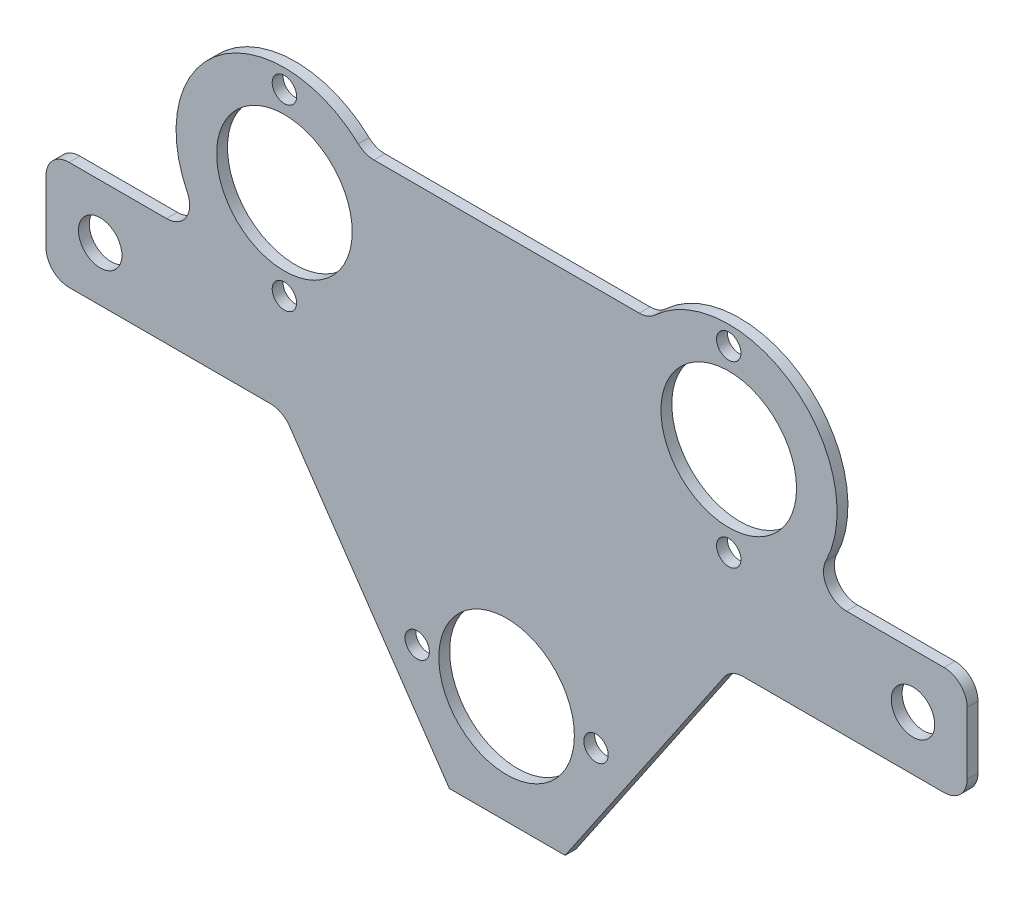
from build123d import *

# Parameters (mm, degrees)
SKETCH1_R           = 12.51
SKETCH1_R_2         = 4.01
BOSS_EXTRUDE1_DEPTH = 2
FILLET1_R           = 4.25
CUT_EXTRUDE1_REACH  = 4
SKETCH2_R           = 2.25


with BuildPart() as part:
    # Sketch1 → Boss-Extrude1 (new body)
    with BuildSketch(Plane.XY):
        with BuildLine():
            ThreePointArc((-26.243645437, 38.5), (-53.422989473, 40.673842303), (-57.51289283, 13.716189899))
            Line((-57.51289283, 13.716189899), (-54.973496399, 10))
            Line((-54.973496399, 10), (-85, 10))
            Line((-85, 10), (-85, -10))
            Line((-85, -10), (-41.306829732, -10))
            Line((-41.306829732, -10), (-10.556829732, -55))
            Line((-10.556829732, -55), (10.805406659, -55))
            Line((10.805406659, -55), (41.391170475, -10))
            Line((41.391170475, -10), (85, -10))
            Line((85, -10), (85, 10))
            Line((85, 10), (54.984843282, 10))
            Line((54.984843282, 10), (57.38463841, 13.530753113))
            ThreePointArc((57.38463841, 13.530753113), (53.511141019, 40.603568515), (26.243645437, 38.5))
            Line((26.243645437, 38.5), (-26.243645437, 38.5))
        make_face()
        with Locations((0, -35)):
            Circle(SKETCH1_R, mode=Mode.SUBTRACT)
        with Locations((-75, 0)):
            Circle(SKETCH1_R_2, mode=Mode.SUBTRACT)
        with Locations((-41, 25)):
            Circle(SKETCH1_R, mode=Mode.SUBTRACT)
        with Locations((75, 0)):
            Circle(SKETCH1_R_2, mode=Mode.SUBTRACT)
        with Locations((41, 25)):
            Circle(SKETCH1_R, mode=Mode.SUBTRACT)
    extrude(amount=BOSS_EXTRUDE1_DEPTH)

    # Fillet1
    fillet1_edges = [part.edges().sort_by_distance(p)[0] for p in [
        (-85, -10, 1),
        (-85, 10, 1),
        (85, -10, 1),
        (85, 10, 1),
        (54.984843282, 10, 1),
        (-54.973496399, 10, 1),
        (41.391170475, -10, 1),
        (-41.306829732, -10, 1),
        (26.243645437, 38.5, 1),
        (-26.243645437, 38.5, 1),
    ]]
    fillet(fillet1_edges, radius=FILLET1_R)

    # Sketch2 → Cut-Extrude1 (cut, up to next)
    with BuildSketch(Plane.XY.offset(2), mode=Mode.PRIVATE) as cut_extrude1_sk1:
        with Locations((-41, 41.5)):
            Circle(SKETCH2_R)
    cut_extrude1_tool1 = extrude(cut_extrude1_sk1.sketch, amount=-CUT_EXTRUDE1_REACH, mode=Mode.PRIVATE) & part.part
    add(cut_extrude1_tool1.solids().sort_by_distance((-41, 41.5, 2))[0], mode=Mode.SUBTRACT)
    # Sketch2 → Cut-Extrude1 (cut, up to next)
    with BuildSketch(Plane.XY.offset(2), mode=Mode.PRIVATE) as cut_extrude1_sk2:
        with Locations((-41, 8.5)):
            Circle(SKETCH2_R)
    cut_extrude1_tool2 = extrude(cut_extrude1_sk2.sketch, amount=-CUT_EXTRUDE1_REACH, mode=Mode.PRIVATE) & part.part
    add(cut_extrude1_tool2.solids().sort_by_distance((-41, 8.5, 2))[0], mode=Mode.SUBTRACT)
    # Sketch2 → Cut-Extrude1 (cut, up to next)
    with BuildSketch(Plane.XY.offset(2), mode=Mode.PRIVATE) as cut_extrude1_sk3:
        with Locations((-16.5, -35)):
            Circle(SKETCH2_R)
    cut_extrude1_tool3 = extrude(cut_extrude1_sk3.sketch, amount=-CUT_EXTRUDE1_REACH, mode=Mode.PRIVATE) & part.part
    add(cut_extrude1_tool3.solids().sort_by_distance((-16.5, -35, 2))[0], mode=Mode.SUBTRACT)
    # Sketch2 → Cut-Extrude1 (cut, up to next)
    with BuildSketch(Plane.XY.offset(2), mode=Mode.PRIVATE) as cut_extrude1_sk4:
        with Locations((16.5, -35)):
            Circle(SKETCH2_R)
    cut_extrude1_tool4 = extrude(cut_extrude1_sk4.sketch, amount=-CUT_EXTRUDE1_REACH, mode=Mode.PRIVATE) & part.part
    add(cut_extrude1_tool4.solids().sort_by_distance((16.5, -35, 2))[0], mode=Mode.SUBTRACT)
    # Sketch2 → Cut-Extrude1 (cut, up to next)
    with BuildSketch(Plane.XY.offset(2), mode=Mode.PRIVATE) as cut_extrude1_sk5:
        with Locations((41, 8.5)):
            Circle(SKETCH2_R)
    cut_extrude1_tool5 = extrude(cut_extrude1_sk5.sketch, amount=-CUT_EXTRUDE1_REACH, mode=Mode.PRIVATE) & part.part
    add(cut_extrude1_tool5.solids().sort_by_distance((41, 8.5, 2))[0], mode=Mode.SUBTRACT)
    # Sketch2 → Cut-Extrude1 (cut, up to next)
    with BuildSketch(Plane.XY.offset(2), mode=Mode.PRIVATE) as cut_extrude1_sk6:
        with Locations((41, 41.5)):
            Circle(SKETCH2_R)
    cut_extrude1_tool6 = extrude(cut_extrude1_sk6.sketch, amount=-CUT_EXTRUDE1_REACH, mode=Mode.PRIVATE) & part.part
    add(cut_extrude1_tool6.solids().sort_by_distance((41, 41.5, 2))[0], mode=Mode.SUBTRACT)


solid = part.part
